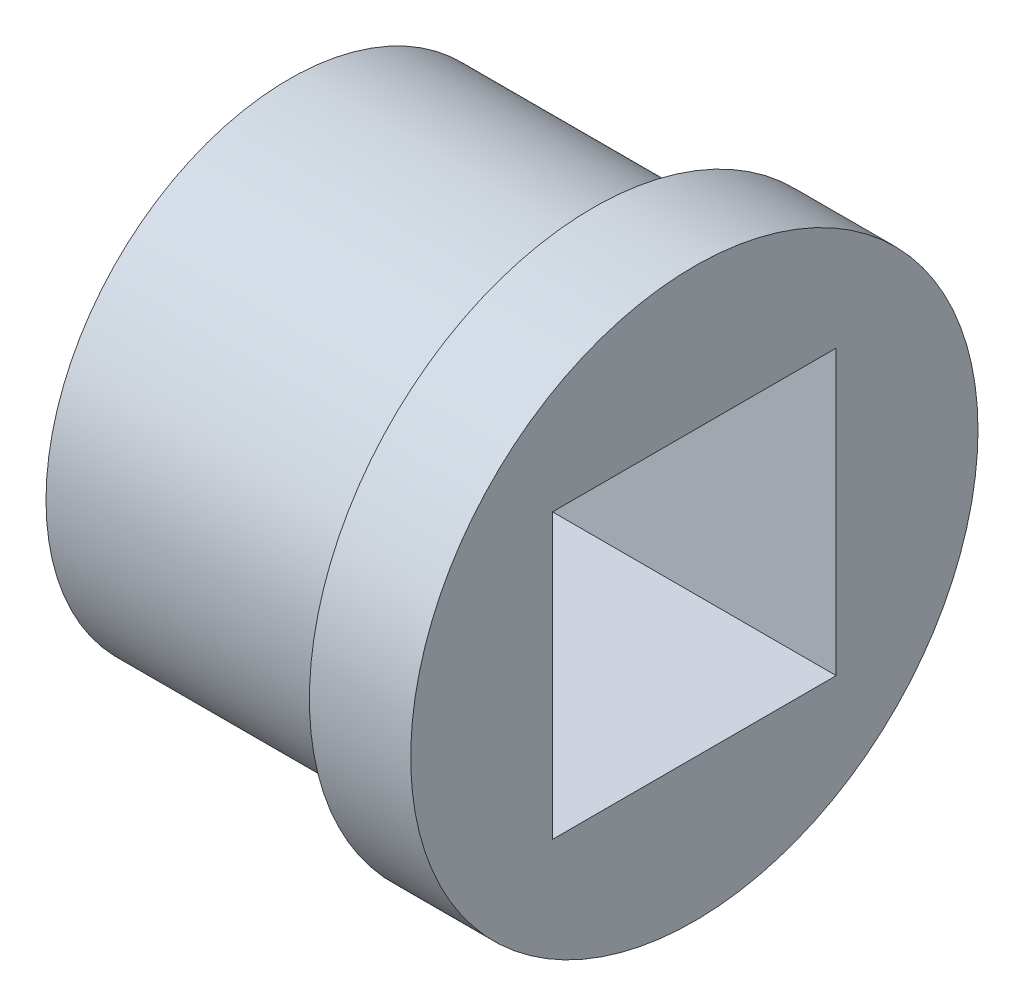
from build123d import *

# Parameters (mm, degrees)
SKETCH2_R           = 3.048
BOSS_EXTRUDE1_DEPTH = 3.81
SKETCH3_R           = 3.556
BOSS_EXTRUDE2_DEPTH = 1.27
SKETCH4_W           = 3.556
SKETCH4_H           = 3.556
CUT_EXTRUDE1_DEPTH  = 6.08


with BuildPart() as part:
    # Sketch2 → Boss-Extrude1 (new body)
    with BuildSketch(Plane(origin=(0, 0, 0), x_dir=(0, 0, -1), z_dir=(1, 0, 0))):
        Circle(SKETCH2_R)
    extrude(amount=BOSS_EXTRUDE1_DEPTH)

    # Sketch3 → Boss-Extrude2 (add)
    with BuildSketch(Plane(origin=(3.81, 0, 0), x_dir=(0, 0, -1), z_dir=(1, 0, 0))):
        Circle(SKETCH3_R)
    extrude(amount=BOSS_EXTRUDE2_DEPTH)

    # Sketch4 → Cut-Extrude1 (cut, through all)
    with BuildSketch(Plane.ZY):
        Rectangle(SKETCH4_W, SKETCH4_H)
    extrude(amount=-CUT_EXTRUDE1_DEPTH, mode=Mode.SUBTRACT)


solid = part.part
